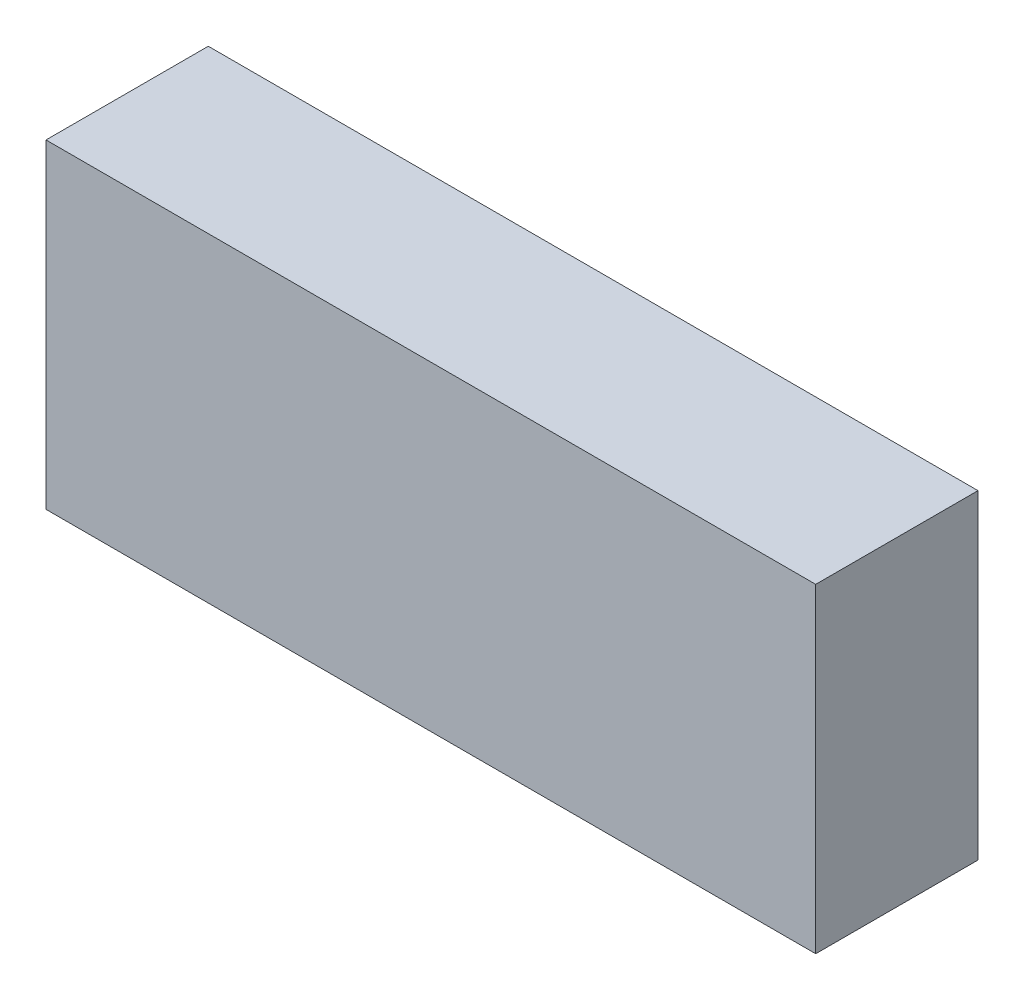
from build123d import *

# Parameters (mm, degrees)
SKETCH1_W           = 166
SKETCH1_H           = 35
BOSS_EXTRUDE1_DEPTH = 69


with BuildPart() as part:
    # Sketch1 → Boss-Extrude1 (new body)
    with BuildSketch(Plane(origin=(0, 0, 0), x_dir=(1, 0, 0), z_dir=(0, 1, 0))):
        with Locations((83, 17.5)):
            Rectangle(SKETCH1_W, SKETCH1_H)
    extrude(amount=BOSS_EXTRUDE1_DEPTH)


solid = part.part
